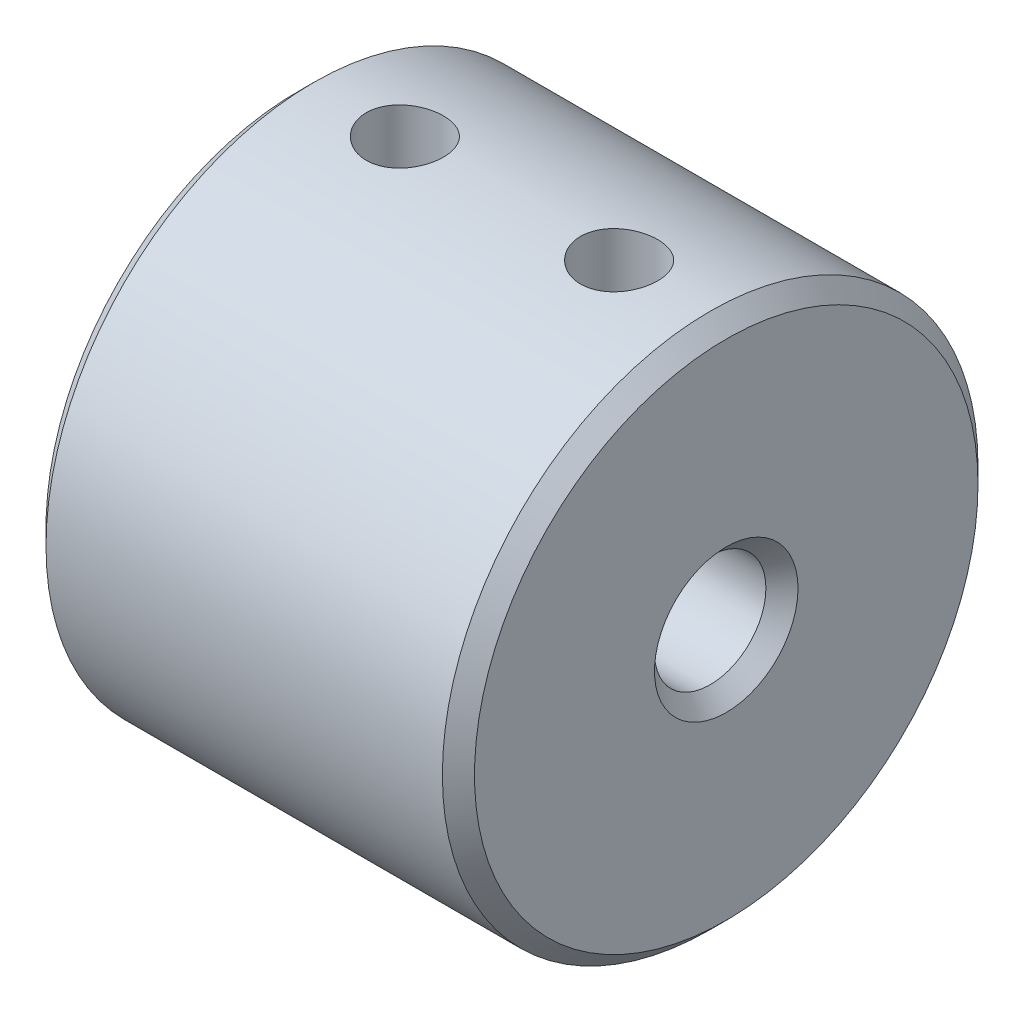
from build123d import *

# Parameters (mm, degrees)
SKETCH1_R           = 12.5
SKETCH1_R_2         = 5.1
BOSS_EXTRUDE1_DEPTH = 20
SKETCH2_R           = 5.1
SKETCH2_R_2         = 2.6
BOSS_EXTRUDE2_DEPTH = 10
CUT_EXTRUDE1_REACH  = 14.5
SKETCH3_R           = 1.8
CHAMFER1_SIZE       = 0.75


with BuildPart() as part:
    # Sketch1 → Boss-Extrude1 (new body)
    with BuildSketch(Plane(origin=(0, 0, 0), x_dir=(0, 0, -1), z_dir=(1, 0, 0))):
        Circle(SKETCH1_R)
        Circle(SKETCH1_R_2, mode=Mode.SUBTRACT)
    extrude(amount=BOSS_EXTRUDE1_DEPTH)

    # Sketch2 → Boss-Extrude2 (add)
    with BuildSketch(Plane(origin=(20, 0, 0), x_dir=(0, 0, -1), z_dir=(1, 0, 0))):
        Circle(SKETCH2_R)
        Circle(SKETCH2_R_2, mode=Mode.SUBTRACT)
    extrude(amount=-BOSS_EXTRUDE2_DEPTH)

    # Sketch3 → Cut-Extrude1 (cut, up to next)
    with BuildSketch(Plane(origin=(0, 0, 0), x_dir=(1, 0, 0), z_dir=(0, 1, 0)), mode=Mode.PRIVATE) as cut_extrude1_sk1:
        with Locations((5, 0)):
            Circle(SKETCH3_R)
    cut_extrude1_tool1 = extrude(cut_extrude1_sk1.sketch, amount=CUT_EXTRUDE1_REACH, mode=Mode.PRIVATE) & part.part
    add(cut_extrude1_tool1.solids().sort_by_distance((5, 0, 0))[0], mode=Mode.SUBTRACT)
    # Sketch3 → Cut-Extrude1 (cut, up to next)
    with BuildSketch(Plane(origin=(0, 0, 0), x_dir=(1, 0, 0), z_dir=(0, 1, 0)), mode=Mode.PRIVATE) as cut_extrude1_sk2:
        with Locations((15, 0)):
            Circle(SKETCH3_R)
    cut_extrude1_tool2 = extrude(cut_extrude1_sk2.sketch, amount=CUT_EXTRUDE1_REACH, mode=Mode.PRIVATE) & part.part
    add(cut_extrude1_tool2.solids().sort_by_distance((15, 0, 0))[0], mode=Mode.SUBTRACT)

    # Chamfer1
    chamfer1_edges = [part.edges().sort_by_distance(p)[0] for p in [
        (10, 0, 5.1),
        (20, 0, 2.6),
        (0, 0, 12.5),
        (20, 0, 12.5),
        (0, 0, 5.1),
    ]]
    chamfer(chamfer1_edges, length=CHAMFER1_SIZE)


solid = part.part
